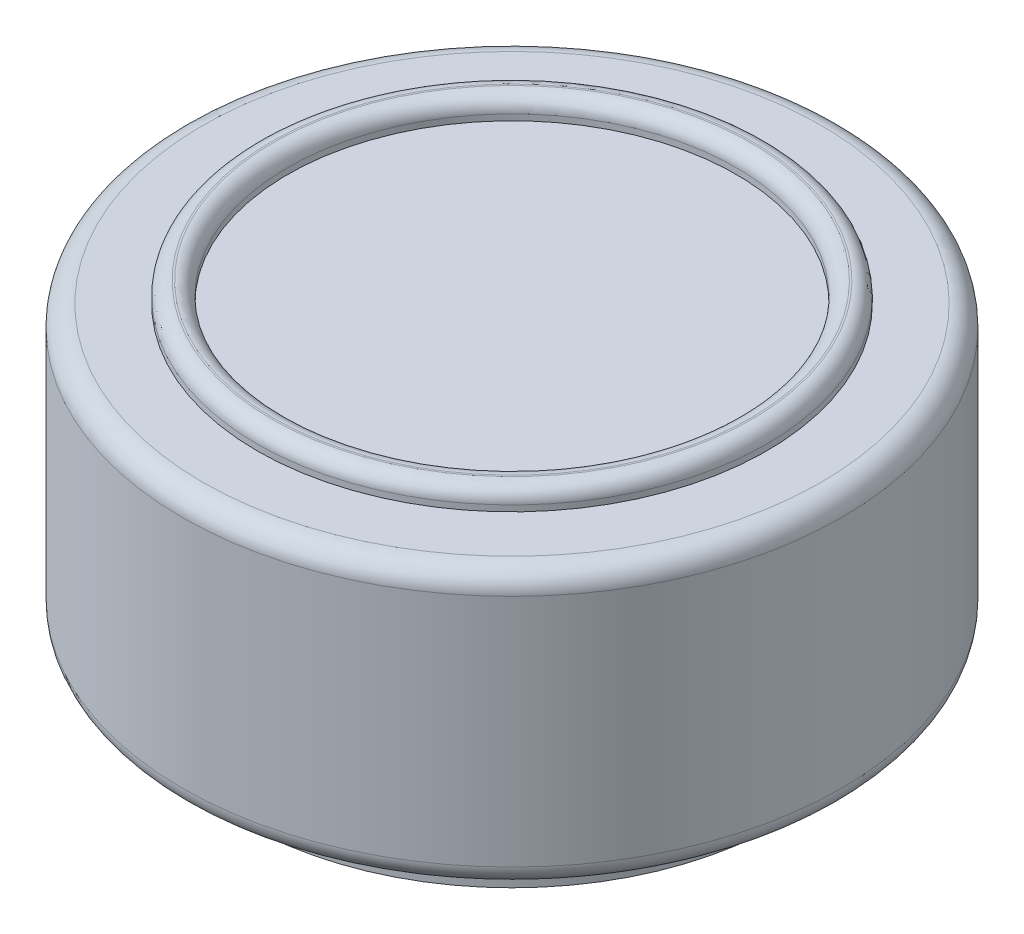
from build123d import *

# Parameters (mm, degrees)
SKETCH1_R           = 16.1655
BOSS_EXTRUDE1_DEPTH = 13.5
FILLET1_R           = 1
SKETCH2_R           = 12.5
SKETCH2_R_2         = 11
BOSS_EXTRUDE2_DEPTH = 1
FILLET4_R           = 0.707
SKETCH3_R           = 13.168514768
BOSS_EXTRUDE3_DEPTH = 2


with BuildPart() as part:
    # Sketch1 → Boss-Extrude1 (new body)
    with BuildSketch(Plane(origin=(0, 0, 0), x_dir=(1, 0, 0), z_dir=(0, 1, 0))):
        Circle(SKETCH1_R)
    extrude(amount=BOSS_EXTRUDE1_DEPTH)

    # Fillet1
    fillet1_edges = [part.edges().sort_by_distance(p)[0] for p in [
        (-16.1655, 0, 0),
        (-16.1655, 13.5, 0),
    ]]
    fillet(fillet1_edges, radius=FILLET1_R)

    # Sketch2 → Boss-Extrude2 (add)
    with BuildSketch(Plane(origin=(0, 13.5, 0), x_dir=(1, 0, 0), z_dir=(0, 1, 0))):
        Circle(SKETCH2_R)
        Circle(SKETCH2_R_2, mode=Mode.SUBTRACT)
    extrude(amount=BOSS_EXTRUDE2_DEPTH)

    # Fillet4
    fillet4_edges = [part.edges().sort_by_distance(p)[0] for p in [
        (-12.5, 14.5, 0),
        (-11, 14.5, 0),
    ]]
    fillet(fillet4_edges, radius=FILLET4_R)

    # Sketch3 → Boss-Extrude3 (add)
    with BuildSketch(Plane.XZ):
        Circle(SKETCH3_R)
    extrude(amount=BOSS_EXTRUDE3_DEPTH)


solid = part.part
